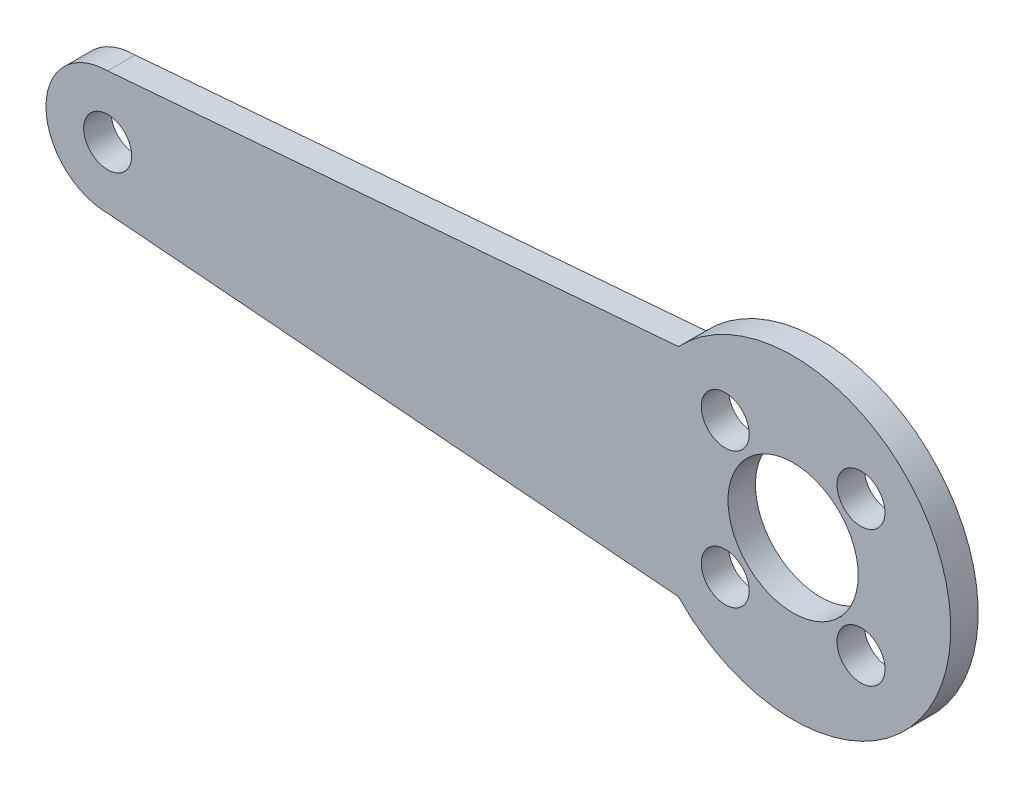
from build123d import *

# Parameters (mm, degrees)
SKETCH_1_R          = 1.75
EXTRUDE_1_DEPTH     = 2
SKETCH_2_R          = 4.75
CUT_EXTRUDE_1_DEPTH = 2


with BuildPart() as part:
    # 草图1 → 凸台-拉伸1 (new body)
    with BuildSketch(Plane.XY):
        with BuildLine():
            Line((-50, 4.5), (-8.354386795, 7.90279832))
            ThreePointArc((-8.354386795, 7.90279832), (11.5, 0), (-8.354386795, -7.90279832))
            Line((-8.354386795, -7.90279832), (-50, -4.5))
            ThreePointArc((-50, -4.5), (-54.5, 0), (-50, 4.5))
        make_face()
        with Locations((-50, 0)):
            Circle(SKETCH_1_R, mode=Mode.SUBTRACT)
        with Locations((4.949747468, 4.949747468)):
            Circle(SKETCH_1_R, mode=Mode.SUBTRACT)
        with Locations((4.949747468, -4.949747468)):
            Circle(SKETCH_1_R, mode=Mode.SUBTRACT)
        with Locations((-4.949747468, -4.949747468)):
            Circle(SKETCH_1_R, mode=Mode.SUBTRACT)
        with Locations((-4.949747468, 4.949747468)):
            Circle(SKETCH_1_R, mode=Mode.SUBTRACT)
    extrude(amount=EXTRUDE_1_DEPTH)

    # 草图2 → 切除-拉伸1 (cut)
    with BuildSketch(Plane.XY.offset(2)):
        Circle(SKETCH_2_R)
    extrude(amount=-CUT_EXTRUDE_1_DEPTH, mode=Mode.SUBTRACT)


solid = part.part
